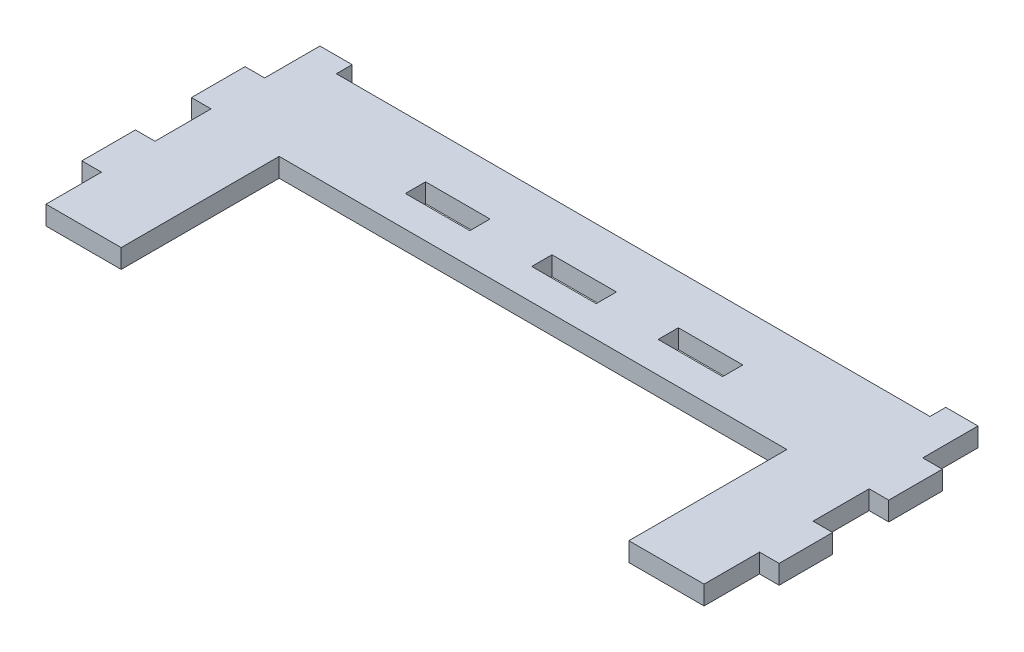
from build123d import *

# Parameters (mm, degrees)
BOSS_EXTRUDE1_DEPTH = 3
SKETCH2_W           = 3.2
SKETCH2_H           = 8.875
SKETCH2_W_2         = 10.2
SKETCH2_H_2         = 3.2
CUT_EXTRUDE1_DEPTH  = 4


with BuildPart() as part:
    # Sketch1 → Boss-Extrude1 (new body)
    with BuildSketch(Plane(origin=(0, 0, 0), x_dir=(1, 0, 0), z_dir=(0, 1, 0))):
        Polygon((-40.172217102, 0), (-55.172217102, 0), (-55.172217102, 43.95), (55.172217102, 43.95), (55.172217102, 0), (40.172217102, 0), (40.172217102, 25), (-40.172217102, 25), align=None)
    extrude(amount=-BOSS_EXTRUDE1_DEPTH)

    # Sketch2 → Cut-Extrude1 (cut, through all)
    with BuildSketch(Plane(origin=(0, 0, 0), x_dir=(1, 0, 0), z_dir=(0, 1, 0))):
        Polygon((-46.972217102, 40.85), (46.972217102, 40.85), (46.972217102, 43.35), (52.072217102, 43.35), (52.072217102, 34.6), (55.272217102, 34.6), (55.272217102, 44.05), (-55.272217102, 44.05), (-55.272217102, 34.6), (-52.072217102, 34.6), (-52.072217102, 43.35), (-46.972217102, 43.35), align=None)
        with Locations((-53.672217102, 21.6875)):
            Rectangle(SKETCH2_W, SKETCH2_H)
        with Locations((-53.672217102, 4.3375)):
            Rectangle(SKETCH2_W, SKETCH2_H)
        with Locations((53.672217102, 4.3375)):
            Rectangle(SKETCH2_W, SKETCH2_H)
        with Locations((53.672217102, 21.6875)):
            Rectangle(SKETCH2_W, SKETCH2_H)
        with Locations((-20, 31.5)):
            Rectangle(SKETCH2_W_2, SKETCH2_H_2)
        with Locations((20, 31.5)):
            Rectangle(SKETCH2_W_2, SKETCH2_H_2)
        with Locations((0, 31.5)):
            Rectangle(SKETCH2_W_2, SKETCH2_H_2)
    extrude(amount=-CUT_EXTRUDE1_DEPTH, mode=Mode.SUBTRACT)


solid = part.part
